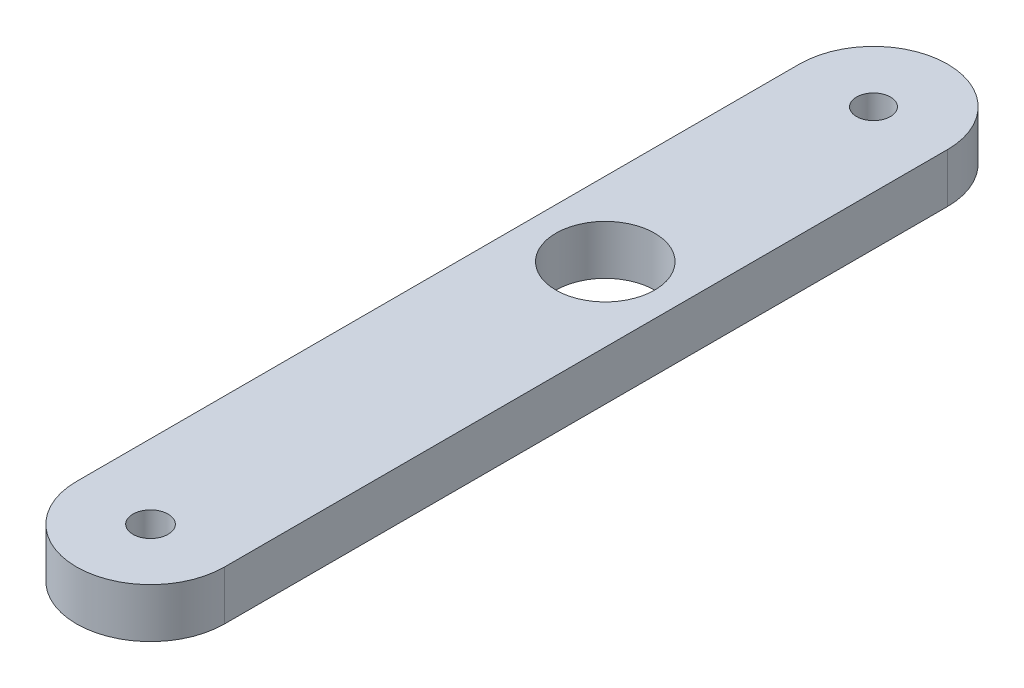
from build123d import *

# Parameters (mm, degrees)
SKETCH2_R           = 1.0922
SKETCH2_R_2         = 3.175
SKETCH2_R_3         = 1.1303
BOSS_EXTRUDE2_DEPTH = 3.175


with BuildPart() as part:
    # Sketch2 → Boss-Extrude2 (new body)
    with BuildSketch(Plane(origin=(0, 0, 0), x_dir=(1, 0, 0), z_dir=(0, 1, 0))):
        with BuildLine():
            Line((-6.706711203, 20.043284588), (-6.706711203, -6.456715412))
            Line((-6.706711203, -6.456715412), (-6.706711203, -26.456715412))
            ThreePointArc((-6.706711203, -26.456715412), (-11.469211203, -31.219215412), (-16.231711203, -26.456715412))
            Line((-16.231711203, -26.456715412), (-16.231711203, -6.456715412))
            Line((-16.231711203, -6.456715412), (-16.231711203, 20.043284588))
            ThreePointArc((-16.231711203, 20.043284588), (-11.469211203, 24.805784588), (-6.706711203, 20.043284588))
        make_face()
        with Locations((-11.469211203, 20.043284588)):
            Circle(SKETCH2_R, mode=Mode.SUBTRACT)
        with Locations((-11.469211203, 2.793284588)):
            Circle(SKETCH2_R_2, mode=Mode.SUBTRACT)
        with Locations((-11.469211203, -26.456715412)):
            Circle(SKETCH2_R_3, mode=Mode.SUBTRACT)
    extrude(amount=BOSS_EXTRUDE2_DEPTH)


solid = part.part
